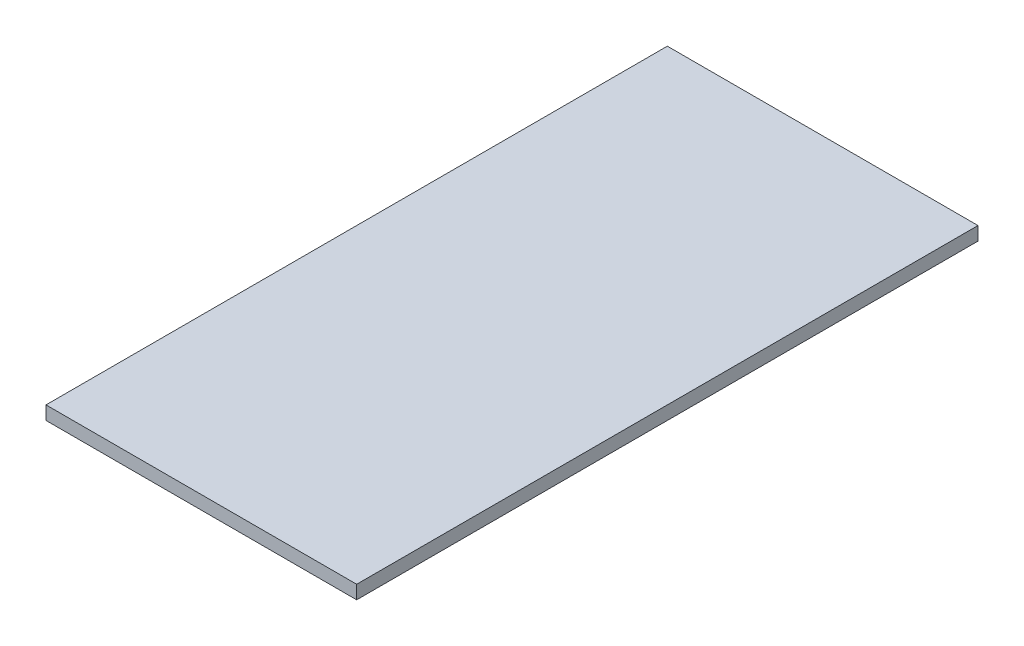
from build123d import *

# Parameters (mm, degrees)
SKETCH1_W           = 115
SKETCH1_H           = 230
BOSS_EXTRUDE1_DEPTH = 5


with BuildPart() as part:
    # Sketch1 → Boss-Extrude1 (new body)
    with BuildSketch(Plane(origin=(0, 0, 0), x_dir=(1, 0, 0), z_dir=(0, 1, 0))):
        Rectangle(SKETCH1_W, SKETCH1_H)
    extrude(amount=BOSS_EXTRUDE1_DEPTH)


solid = part.part
